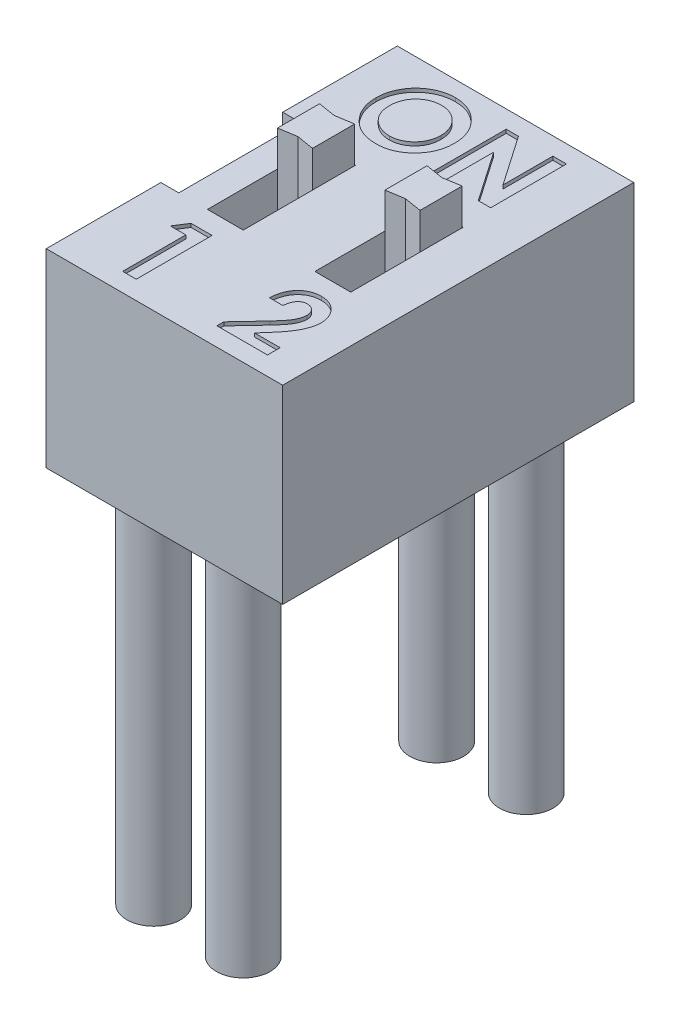
from build123d import *

# Parameters (mm, degrees)
BOSS_EXTRUDE1_DEPTH   = 5.3
SKETCH2_W             = 1
SKETCH2_H             = 3.14
CUT_EXTRUDE1_DEPTH    = 1
BOSS_EXTRUDE2_DEPTH   = 2
SKETCH4_W             = 3.4
SKETCH4_H             = 2
BOSS_EXTRUDE3_DEPTH   = 0.5
CUT_EXTRUDE2_DEPTH    = 0.1
SKETCH6_W             = 0.5
SKETCH6_H             = 0.1
BOSS_EXTRUDE4_DEPTH   = 3.5
SKETCH7_R             = 0.75
BOSS_EXTRUDE5_DEPTH   = 10
BOSS_EXTRUDE5_2_DEPTH = 10
BOSS_EXTRUDE5_3_DEPTH = 10
BOSS_EXTRUDE5_4_DEPTH = 10


with BuildPart() as part:
    # Sketch1 → Boss-Extrude1 (new body)
    with BuildSketch(Plane(origin=(0, 0, 0), x_dir=(1, 0, 0), z_dir=(0, 1, 0))):
        Polygon((-3.3, 1.7), (-3.3, 4.9), (3.3, 4.9), (3.3, -4.9), (-3.3, -4.9), (-3.3, -1.7), (-2.8, -1.7), (-2.8, 1.7), align=None)
    extrude(amount=BOSS_EXTRUDE1_DEPTH)

    # Sketch2 → Cut-Extrude1 (cut)
    with BuildSketch(Plane(origin=(0, 5.3, 0), x_dir=(1, 0, 0), z_dir=(0, 1, 0))):
        with Locations((-1.5, -0.13)):
            Rectangle(SKETCH2_W, SKETCH2_H)
        with Locations((1.5, -0.13)):
            Rectangle(SKETCH2_W, SKETCH2_H)
    extrude(amount=-CUT_EXTRUDE1_DEPTH, mode=Mode.SUBTRACT)

    # Sketch3 → Boss-Extrude2 (add)
    with BuildSketch(Plane(origin=(0, 4.3, 0), x_dir=(1, 0, 0), z_dir=(0, 1, 0))):
        Polygon((-1.99, 1.42), (-1.99, 0.243514995), (-1.5, 0.323514995), (-1.01, 0.243514995), (-1.01, 1.42), (-1.5, 1.34), align=None)
        Polygon((1.5, 1.34), (1.99, 1.42), (1.99, 0.243514995), (1.5, 0.323514995), (1.01, 0.243514995), (1.01, 1.42), align=None)
    extrude(amount=BOSS_EXTRUDE2_DEPTH)

    # Sketch4 → Boss-Extrude3 (add)
    with BuildSketch(Plane.ZY.offset(2.8)):
        with Locations((0, 1)):
            Rectangle(SKETCH4_W, SKETCH4_H)
    extrude(amount=BOSS_EXTRUDE3_DEPTH)

    # Sketch5 → Cut-Extrude2 (cut)
    with BuildSketch(Plane(origin=(0, 5.3, 0), x_dir=(1, 0, 0), z_dir=(0, 1, 0))):
        with BuildLine():
            add(Edge.make_bspline(
                [(-1.243798498, 4.46265431), (-1.206997654, 4.46170147), (-1.134344452, 4.459820349), (-1.027497811, 4.444139733), (-0.924531316, 4.418590418), (-0.825491528, 4.383075021), (-0.730626433, 4.336631607), (-0.639601408, 4.280576875), (-0.552742502, 4.213852826), (-0.470939775, 4.138016023), (-0.395339301, 4.055546811), (-0.329831447, 3.966754043), (-0.273968752, 3.873938427), (-0.227669601, 3.776851263), (-0.19240418, 3.674820175), (-0.167656975, 3.568365387), (-0.151758122, 3.457517184), (-0.149929509, 3.382044667), (-0.149000154, 3.343687296)],
                knots=[0, 0, 0, 0, 0.00011036, 0.000217876, 0.000323183, 0.000428201, 0.00053288, 0.000639492, 0.000748383, 0.000860906, 0.000973768, 0.001083504, 0.001191344, 0.001298316, 0.001405592, 0.001514507, 0.001625802, 0.001740821, 0.001740821, 0.001740821, 0.001740821], degree=3))
            add(Edge.make_bspline(
                [(-0.149000154, 3.343687296), (-0.149989877, 3.305762125), (-0.151940158, 3.231029358), (-0.167007914, 3.121202665), (-0.192171865, 3.015888229), (-0.226839157, 2.914847669), (-0.272298616, 2.818570391), (-0.327071928, 2.726441678), (-0.392604455, 2.639316505), (-0.46650597, 2.557241629), (-0.547865124, 2.482741067), (-0.634037383, 2.417087576), (-0.724624858, 2.361455285), (-0.819494958, 2.315869676), (-0.918851126, 2.280492365), (-1.02244794, 2.2555311), (-1.130278991, 2.240361636), (-1.203609335, 2.238424094), (-1.240830416, 2.237440635)],
                knots=[0, 0, 0, 0, 0.000113749, 0.000224146, 0.000331823, 0.000438159, 0.000544002, 0.000650679, 0.000759142, 0.000870521, 0.000981559, 0.001089599, 0.001195044, 0.00129992, 0.001404796, 0.001510824, 0.001619121, 0.001730752, 0.001730752, 0.001730752, 0.001730752], degree=3))
            add(Edge.make_bspline(
                [(-1.240830416, 2.237440635), (-1.279759203, 2.238322846), (-1.356248948, 2.240056271), (-1.468192033, 2.256540351), (-1.575443181, 2.281371133), (-1.677101421, 2.318429743), (-1.774202054, 2.364756122), (-1.866031655, 2.421809835), (-1.952559363, 2.489496596), (-2.033288839, 2.566082923), (-2.10642994, 2.649885162), (-2.170991309, 2.738414797), (-2.225450255, 2.830995538), (-2.269808773, 2.927670715), (-2.304779246, 3.027839515), (-2.329446941, 3.132111997), (-2.344018737, 3.240238075), (-2.346048504, 3.313679469), (-2.347077077, 3.350895496)],
                knots=[0, 0, 0, 0, 0.000116714, 0.000229327, 0.000338753, 0.000446453, 0.000553225, 0.000661004, 0.000770077, 0.00088225, 0.000994335, 0.001103319, 0.001210509, 0.001315995, 0.00142193, 0.001528272, 0.001636931, 0.001748563, 0.001748563, 0.001748563, 0.001748563], degree=3))
            add(Edge.make_bspline(
                [(-2.347077077, 3.350895496), (-2.346754251, 3.375932491), (-2.346112688, 3.425689455), (-2.338384382, 3.499426736), (-2.327257843, 3.571724765), (-2.310802219, 3.642295287), (-2.290812843, 3.711636146), (-2.264913782, 3.779101899), (-2.235433642, 3.845413266), (-2.200988874, 3.909787026), (-2.162689622, 3.971630889), (-2.120901729, 4.030653124), (-2.075520119, 4.086140067), (-2.026690981, 4.138456356), (-1.974246043, 4.187258111), (-1.918875165, 4.23323619), (-1.859504474, 4.275169251), (-1.797433408, 4.314081383), (-1.733011909, 4.349268949), (-1.666502232, 4.379219553), (-1.599274606, 4.405374905), (-1.530430963, 4.426017866), (-1.460709083, 4.442831341), (-1.38936413, 4.453950381), (-1.317040665, 4.461678473), (-1.268270493, 4.462328259), (-1.243798498, 4.46265431)],
                knots=[0, 0, 0, 0, 7.508e-05, 0.000149209, 0.000222195, 0.000294401, 0.00036645, 0.000438508, 0.000511008, 0.000584038, 0.000657344, 0.000729111, 0.00080083, 0.000872228, 0.000943626, 0.001015614, 0.001087973, 0.001161503, 0.001235308, 0.001307982, 0.001380191, 0.001451549, 0.001523439, 0.001595168, 0.001668032, 0.001741416, 0.001741416, 0.001741416, 0.001741416], degree=3))
        make_face()
        with BuildLine():
            add(Edge.make_bspline(
                [(-1.249734662, 4.08273978), (-1.274501626, 4.082075227), (-1.3233817, 4.080763665), (-1.395079868, 4.070771335), (-1.463912641, 4.054812449), (-1.529498451, 4.031696197), (-1.592121555, 4.002275076), (-1.651892963, 3.966651886), (-1.707984964, 3.923602119), (-1.761145491, 3.875436927), (-1.80916728, 3.821769833), (-1.851596045, 3.764256415), (-1.887102088, 3.70299272), (-1.916838621, 3.638547872), (-1.93922364, 3.570197206), (-1.955167818, 3.49847612), (-1.965243943, 3.423261036), (-1.966514051, 3.371987011), (-1.967162547, 3.345807355)],
                knots=[0, 0, 0, 0, 7.428e-05, 0.000146598, 0.00021674, 0.000285936, 0.00035479, 0.000424017, 0.000494234, 0.000566566, 0.000638929, 0.000709912, 0.000780599, 0.000850993, 0.00092246, 0.000995907, 0.001071167, 0.001149683, 0.001149683, 0.001149683, 0.001149683], degree=3))
            add(Edge.make_bspline(
                [(-1.967162547, 3.345807355), (-1.96630274, 3.316794407), (-1.964617662, 3.259933835), (-1.952761246, 3.176987166), (-1.932476099, 3.098652269), (-1.90318474, 3.025312269), (-1.86685577, 2.95615278), (-1.821740956, 2.89202145), (-1.768570943, 2.832534291), (-1.727609196, 2.797803209), (-1.706819331, 2.780175678)],
                knots=[0, 0, 0, 0, 8.7026e-05, 0.000170556, 0.000250775, 0.000329198, 0.000406967, 0.000484602, 0.000563867, 0.000645559, 0.000645559, 0.000645559, 0.000645559], degree=3))
            add(Edge.make_bspline(
                [(-1.706819331, 2.780175678), (-1.689788463, 2.767153134), (-1.656110434, 2.741401448), (-1.602352968, 2.708395378), (-1.546993364, 2.680105884), (-1.489613863, 2.657248308), (-1.430335649, 2.639268923), (-1.36916685, 2.626678255), (-1.306194137, 2.618776522), (-1.263609037, 2.617832115), (-1.242102451, 2.617355165)],
                knots=[0, 0, 0, 0, 6.4282e-05, 0.000127116, 0.000188935, 0.000250586, 0.000312155, 0.000374524, 0.00043774, 0.00050224, 0.00050224, 0.00050224, 0.00050224], degree=3))
            add(Edge.make_bspline(
                [(-1.242102451, 2.617355165), (-1.217761356, 2.618025353), (-1.169869487, 2.619343969), (-1.099506019, 2.629213287), (-1.032095681, 2.645915737), (-0.967219981, 2.668829205), (-0.905065994, 2.698619734), (-0.845937482, 2.735347844), (-0.789730777, 2.778562561), (-0.736637975, 2.827360268), (-0.688108645, 2.881238773), (-0.645768419, 2.939058961), (-0.609133462, 2.999546881), (-0.5800153, 3.063558648), (-0.5567459, 3.13049002), (-0.540993619, 3.200637423), (-0.530832373, 3.273711681), (-0.529561907, 3.323441296), (-0.528914684, 3.348775437)],
                knots=[0, 0, 0, 0, 7.3009e-05, 0.000143647, 0.000212652, 0.000281048, 0.000349701, 0.000419007, 0.000489481, 0.0005621, 0.000635061, 0.000706637, 0.00077681, 0.000846818, 0.000917215, 0.000989009, 0.001062168, 0.001138141, 0.001138141, 0.001138141, 0.001138141], degree=3))
            add(Edge.make_bspline(
                [(-0.528914684, 3.348775437), (-0.529584301, 3.3739639), (-0.530902341, 3.423543547), (-0.54078903, 3.496429932), (-0.557385557, 3.566267654), (-0.580367832, 3.633170766), (-0.609714979, 3.697204858), (-0.646005705, 3.758144747), (-0.689112668, 3.81593152), (-0.738043764, 3.870171382), (-0.791302256, 3.920014342), (-0.848480568, 3.963268969), (-0.907978788, 4.000855866), (-0.971162094, 4.030299923), (-1.036737809, 4.05375794), (-1.10510608, 4.071032761), (-1.176525856, 4.080693468), (-1.225114207, 4.082051596), (-1.249734662, 4.08273978)],
                knots=[0, 0, 0, 0, 7.555e-05, 0.000148709, 0.000220186, 0.000290584, 0.000360592, 0.000431128, 0.000502957, 0.000576516, 0.000650022, 0.000721428, 0.000791318, 0.000860737, 0.000930074, 0.001000004, 0.001071902, 0.001145758, 0.001145758, 0.001145758, 0.001145758], degree=3))
        make_face(mode=Mode.SUBTRACT)
        Polygon((0.230914376, 4.408380806), (0.57309186, 4.408380806), (1.533478479, 3.0155022), (1.533478479, 4.408380806), (1.913393009, 4.408380806), (1.913393009, 2.291714139), (1.568671454, 2.291714139), (0.610828906, 3.680352627), (0.610828906, 2.291714139), (0.230914376, 2.291714139), align=None)
        Polygon((-1.893457074, -2.264859964), (-1.306200798, -2.264859964), (-1.306200798, -4.381526631), (-1.686115328, -4.381526631), (-1.686115328, -2.617637742), (-2.120303362, -2.617637742), align=None)
        with BuildLine():
            Line((1.380337664, -2.97041552), (1.000423134, -2.97041552))
            add(Edge.make_bspline(
                [(1.000423134, -2.97041552), (1.002063926, -2.941676995), (1.005269937, -2.885523644), (1.018022635, -2.803959104), (1.035110813, -2.726889583), (1.057917255, -2.654584678), (1.086575042, -2.587070662), (1.120346735, -2.524117378), (1.160095123, -2.466056275), (1.204974231, -2.413167357), (1.254222135, -2.36572022), (1.3068164, -2.323650608), (1.363561526, -2.288935822), (1.423420733, -2.260368768), (1.486383829, -2.237545019), (1.553046543, -2.222285496), (1.622831673, -2.211951597), (1.670605245, -2.21104734), (1.694954384, -2.21058646)],
                knots=[0, 0, 0, 0, 8.6309e-05, 0.000168643, 0.000247333, 0.000322964, 0.000395733, 0.000467068, 0.000536927, 0.000606419, 0.000674789, 0.000741804, 0.000808055, 0.000873864, 0.00094052, 0.001008501, 0.00107872, 0.00115171, 0.00115171, 0.00115171, 0.00115171], degree=3))
            add(Edge.make_bspline(
                [(1.694954384, -2.21058646), (1.724842606, -2.211519051), (1.78319142, -2.213339688), (1.867976874, -2.228870324), (1.947157218, -2.254847713), (2.020674896, -2.291144976), (2.087904038, -2.337256844), (2.148833495, -2.392237701), (2.201620665, -2.457241072), (2.246600232, -2.529562274), (2.283972877, -2.606140248), (2.31016207, -2.68532505), (2.327375944, -2.765015434), (2.329211911, -2.818674905), (2.330123989, -2.845332053)],
                knots=[0, 0, 0, 0, 8.9611e-05, 0.000174942, 0.000257538, 0.000338888, 0.000420037, 0.000501382, 0.000584229, 0.000670344, 0.000756444, 0.000839174, 0.000920085, 0.000999961, 0.000999961, 0.000999961, 0.000999961], degree=3))
            add(Edge.make_bspline(
                [(2.330123989, -2.845332053), (2.329768874, -2.861456179), (2.329054115, -2.893910064), (2.324084302, -2.943020756), (2.316628601, -2.993045738), (2.30538722, -3.043942118), (2.291368297, -3.095724163), (2.274361317, -3.148546838), (2.253971786, -3.202110659), (2.230539965, -3.257018477), (2.202585742, -3.313448556), (2.170036936, -3.372246806), (2.132029627, -3.433361067), (2.089022895, -3.497136411), (2.040807867, -3.563472254), (1.987149174, -3.632168771), (1.928664836, -3.703468028), (1.887156857, -3.75112758), (1.86583112, -3.775613837)],
                knots=[0, 0, 0, 0, 4.8367e-05, 9.7351e-05, 0.000147963, 0.000200025, 0.000253614, 0.000308859, 0.000366426, 0.000425498, 0.000487885, 0.000555262, 0.00062704, 0.000703716, 0.000785984, 0.000873005, 0.00096519, 0.001062598, 0.001062598, 0.001062598, 0.001062598], degree=3))
            Line((1.86583112, -3.775613837), (1.644920997, -4.028748853))
            Line((1.644920997, -4.028748853), (2.357260741, -4.028748853))
            Line((2.357260741, -4.028748853), (2.357260741, -4.381526631))
            Line((2.357260741, -4.381526631), (0.94614963, -4.381526631))
            Line((0.94614963, -4.381526631), (0.94614963, -4.189025295))
            Line((0.94614963, -4.189025295), (1.572838999, -3.522054809))
            add(Edge.make_bspline(
                [(1.572838999, -3.522054809), (1.590983267, -3.502599073), (1.626123333, -3.464919082), (1.676124025, -3.409582006), (1.721370235, -3.357068441), (1.760923745, -3.306819226), (1.796860273, -3.260464238), (1.827577411, -3.216606281), (1.853356199, -3.175641848), (1.881342728, -3.126245895), (1.907920732, -3.067332432), (1.932307659, -2.999461706), (1.947173178, -2.934592924), (1.94922509, -2.892323031), (1.950209459, -2.872044793)],
                knots=[0, 0, 0, 0, 7.9809e-05, 0.000154566, 0.000223736, 0.000287704, 0.00034639, 0.000399675, 0.000448261, 0.000491546, 0.000569905, 0.000641782, 0.000707734, 0.000768546, 0.000768546, 0.000768546, 0.000768546], degree=3))
            add(Edge.make_bspline(
                [(1.950209459, -2.872044793), (1.94947347, -2.852427163), (1.948047374, -2.814414858), (1.932375735, -2.760342558), (1.908096689, -2.71138561), (1.873884084, -2.669006903), (1.832441904, -2.634181509), (1.784551572, -2.60827936), (1.730603536, -2.593333938), (1.692784934, -2.591463306), (1.673329785, -2.59050099)],
                knots=[0, 0, 0, 0, 5.8699e-05, 0.000113739, 0.000167403, 0.000221703, 0.000275884, 0.00032881, 0.00038385, 0.000442162, 0.000442162, 0.000442162, 0.000442162], degree=3))
            add(Edge.make_bspline(
                [(1.673329785, -2.59050099), (1.663279006, -2.590856481), (1.643492435, -2.591556322), (1.614407723, -2.596214975), (1.586731529, -2.604425365), (1.560155803, -2.615426133), (1.534964168, -2.630007729), (1.511220164, -2.647981869), (1.48867362, -2.668891789), (1.467427941, -2.692672108), (1.448091601, -2.719210951), (1.430917134, -2.748265939), (1.416716709, -2.779819038), (1.404214138, -2.813453698), (1.394571558, -2.849531184), (1.387550563, -2.887835575), (1.382212969, -2.928304555), (1.380974137, -2.956123174), (1.380337664, -2.97041552)],
                knots=[0, 0, 0, 0, 3.0153e-05, 5.936e-05, 8.8074e-05, 0.000116581, 0.000145454, 0.000175135, 0.00020574, 0.000237572, 0.000270648, 0.000304099, 0.00033863, 0.000374312, 0.000411649, 0.000450485, 0.000491086, 0.000533987, 0.000533987, 0.000533987, 0.000533987], degree=3))
        make_face()
    extrude(amount=-CUT_EXTRUDE2_DEPTH, mode=Mode.SUBTRACT)

    # Sketch6 → Boss-Extrude4 (add)
    with BuildSketch(Plane.XZ):
        with Locations((-1.25, 3.95)):
            Rectangle(SKETCH6_W, SKETCH6_H)
        with Locations((1.25, 3.95)):
            Rectangle(SKETCH6_W, SKETCH6_H)
        with Locations((-1.25, -3.95)):
            Rectangle(SKETCH6_W, SKETCH6_H)
        with Locations((1.25, -3.95)):
            Rectangle(SKETCH6_W, SKETCH6_H)
    extrude(amount=BOSS_EXTRUDE4_DEPTH)


with BuildPart() as body_2:
    # Sketch7 → Boss-Extrude5 (new body)
    with BuildSketch(Plane.XZ):
        with Locations((-1.25, 3.95)):
            Circle(SKETCH7_R)
    extrude(amount=BOSS_EXTRUDE5_DEPTH)


with BuildPart() as body_3:
    # Sketch7 → Boss-Extrude5 2 (new body)
    with BuildSketch(Plane.XZ):
        with Locations((1.25, 3.95)):
            Circle(SKETCH7_R)
    extrude(amount=BOSS_EXTRUDE5_2_DEPTH)


with BuildPart() as body_4:
    # Sketch7 → Boss-Extrude5 3 (new body)
    with BuildSketch(Plane.XZ):
        with Locations((-1.25, -3.95)):
            Circle(SKETCH7_R)
    extrude(amount=BOSS_EXTRUDE5_3_DEPTH)


with BuildPart() as body_5:
    # Sketch7 → Boss-Extrude5 4 (new body)
    with BuildSketch(Plane.XZ):
        with Locations((1.25, -3.95)):
            Circle(SKETCH7_R)
    extrude(amount=BOSS_EXTRUDE5_4_DEPTH)


solid = Compound([part.part, body_2.part, body_3.part, body_4.part, body_5.part])
